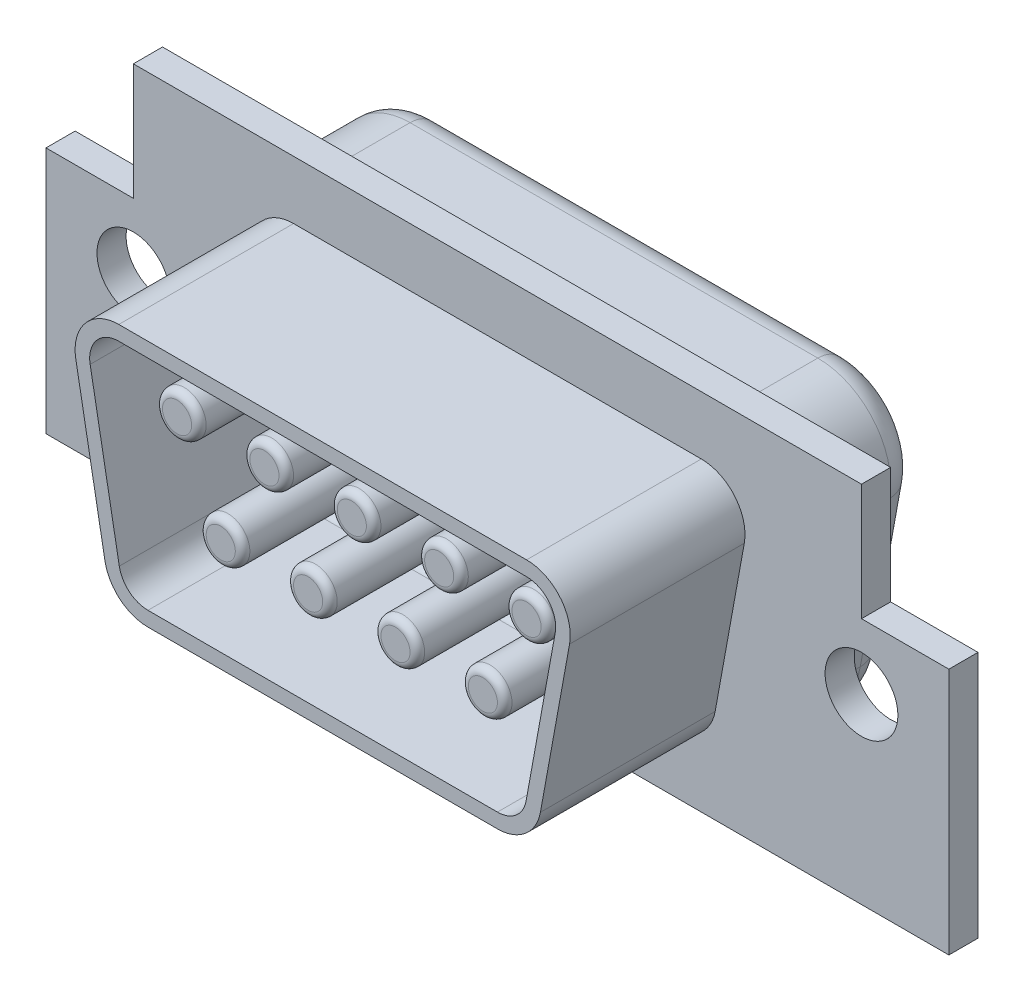
from build123d import *

# Parameters (mm, degrees)
SKETCH1_W                 = 31
SKETCH1_H                 = 12.5
EXTRUDE1_DEPTH            = 1
EXTRUDE2_DEPTH            = 6
M3X0_5_TAPPED_HOLE1_D     = 2.5
M3X0_5_TAPPED_HOLE1_DEPTH = 17.5
M3X0_5_TAPPED_HOLE1_TIP   = 0.751075774
EXTRUDE3_DEPTH            = 4
FILLET2_R                 = 1
EXTRUDE4_DEPTH            = 0.5
SKETCH10_W                = 6.420651052
SKETCH10_H                = 6.175896966
SKETCH10_W_2              = 7.637064352
SKETCH10_H_2              = 8.744155905
CUT_EXTRUDE1_DEPTH        = 5
SKETCH8_R                 = 0.75
EXTRUDE5_DEPTH            = 5
FILLET3_R                 = 0.25


with BuildPart() as part:
    # Sketch1 → Extrude1 (new body)
    with BuildSketch(Plane.XY):
        Rectangle(SKETCH1_W, SKETCH1_H)
    extrude(amount=EXTRUDE1_DEPTH)

    # Sketch2 → Extrude2 (add)
    with BuildSketch(Plane.XY.offset(1)):
        with BuildLine():
            Line((-6, -4.25), (6, -4.25))
            ThreePointArc((6, -4.25), (6.961121159, -3.901627595), (7.475804865, -3.018328157))
            Line((7.475804865, -3.018328157), (8.475804865, 2.481671843))
            ThreePointArc((8.475804865, 2.481671843), (8.151627595, 3.711121159), (7, 4.25))
            Line((7, 4.25), (-7, 4.25))
            ThreePointArc((-7, 4.25), (-8.151627595, 3.711121159), (-8.475804865, 2.481671843))
            Line((-8.475804865, 2.481671843), (-7.475804865, -3.018328157))
            ThreePointArc((-7.475804865, -3.018328157), (-6.961121159, -3.901627595), (-6, -4.25))
        make_face()
        with BuildLine():
            Line((-7, 3.75), (7, 3.75))
            ThreePointArc((7, 3.75), (7.76775173, 3.390747439), (7.98386991, 2.571114562))
            Line((7.98386991, 2.571114562), (6.98386991, -2.928885438))
            ThreePointArc((6.98386991, -2.928885438), (6.640747439, -3.51775173), (6, -3.75))
            Line((6, -3.75), (-6, -3.75))
            ThreePointArc((-6, -3.75), (-6.640747439, -3.51775173), (-6.98386991, -2.928885438))
            Line((-6.98386991, -2.928885438), (-7.98386991, 2.571114562))
            ThreePointArc((-7.98386991, 2.571114562), (-7.76775173, 3.390747439), (-7, 3.75))
        make_face(mode=Mode.SUBTRACT)
    extrude(amount=EXTRUDE2_DEPTH)

    # M3x0.5 Tapped Hole1
    with Locations(Plane(origin=(-12.5, 0, 1), x_dir=(1, 0, 0), z_dir=(0, 0, 1))):
        with Locations((0, 0), (25, 0)):
            Hole(M3X0_5_TAPPED_HOLE1_D / 2, depth=M3X0_5_TAPPED_HOLE1_DEPTH)
            with Locations((0, 0, -(M3X0_5_TAPPED_HOLE1_DEPTH + M3X0_5_TAPPED_HOLE1_TIP / 2))):  # 118° drill point
                Cone(0, M3X0_5_TAPPED_HOLE1_D / 2, M3X0_5_TAPPED_HOLE1_TIP, mode=Mode.SUBTRACT)

    # Sketch6 → Extrude3 (add)
    with BuildSketch(Plane(origin=(0, 0, 0), x_dir=(-1, 0, 0), z_dir=(0, 0, -1))):
        with BuildLine():
            Line((8.459674775, -3.197213595), (9.459674775, 2.302786405))
            ThreePointArc((9.459674775, 2.302786405), (8.919379325, 4.351868598), (7, 5.25))
            Line((7, 5.25), (-7, 5.25))
            ThreePointArc((-7, 5.25), (-8.919379325, 4.351868598), (-9.459674775, 2.302786405))
            Line((-9.459674775, 2.302786405), (-8.459674775, -3.197213595))
            ThreePointArc((-8.459674775, -3.197213595), (-7.601868598, -4.669379325), (-6, -5.25))
            Line((-6, -5.25), (6, -5.25))
            ThreePointArc((6, -5.25), (7.601868598, -4.669379325), (8.459674775, -3.197213595))
        make_face()
    extrude(amount=EXTRUDE3_DEPTH)

    # Fillet2
    fillet2_edges = [part.edges().sort_by_distance(p)[0] for p in [
        (-8.919379325, 4.351868598, -4),
        (0, 5.25, -4),
        (8.919379325, 4.351868598, -4),
        (8.959674775, -0.447213595, -4),
        (7.601868598, -4.669379325, -4),
        (0, -5.25, -4),
        (-7.601868598, -4.669379325, -4),
        (-8.959674775, -0.447213595, -4),
    ]]
    fillet(fillet2_edges, radius=FILLET2_R)

    # Sketch7 → Extrude4 (add)
    with BuildSketch(Plane(origin=(0, 0, -4), x_dir=(-1, 0, 0), z_dir=(0, 0, -1))):
        with BuildLine():
            Line((6.98386991, -2.928885438), (7.98386991, 2.571114562))
            ThreePointArc((7.98386991, 2.571114562), (7.76775173, 3.390747439), (7, 3.75))
            Line((7, 3.75), (-7, 3.75))
            ThreePointArc((-7, 3.75), (-7.76775173, 3.390747439), (-7.98386991, 2.571114562))
            Line((-7.98386991, 2.571114562), (-6.98386991, -2.928885438))
            ThreePointArc((-6.98386991, -2.928885438), (-6.640747439, -3.51775173), (-6, -3.75))
            Line((-6, -3.75), (6, -3.75))
            ThreePointArc((6, -3.75), (6.640747439, -3.51775173), (6.98386991, -2.928885438))
        make_face()
    extrude(amount=EXTRUDE4_DEPTH)

    # Sketch10 → Cut-Extrude1 (cut)
    with BuildSketch(Plane.XY.offset(1)):
        with Locations((-15.710325526, 5.337948483)):
            Rectangle(SKETCH10_W, SKETCH10_H)
        with Locations((16.318532176, 6.622077953)):
            Rectangle(SKETCH10_W_2, SKETCH10_H_2)
    extrude(amount=-CUT_EXTRUDE1_DEPTH, mode=Mode.SUBTRACT)

    # Sketch8 → Extrude5 (add)
    with BuildSketch(Plane.XY.offset(1)):
        with Locations((-6, 1.5)):
            Circle(SKETCH8_R)
        with Locations((-4.5, -1.5)):
            Circle(SKETCH8_R)
        with Locations((-3, 1.5)):
            Circle(SKETCH8_R)
        with Locations((1.5, -1.5)):
            Circle(SKETCH8_R)
        with Locations((0, 1.5)):
            Circle(SKETCH8_R)
        with Locations((-1.5, -1.5)):
            Circle(SKETCH8_R)
        with Locations((3, 1.5)):
            Circle(SKETCH8_R)
        with Locations((4.5, -1.5)):
            Circle(SKETCH8_R)
        with Locations((6, 1.5)):
            Circle(SKETCH8_R)
    extrude(amount=EXTRUDE5_DEPTH)

    # Fillet3
    fillet3_edges = [part.edges().sort_by_distance(p)[0] for p in [
        (-6.75, 1.5, 1),
        (-6.75, 1.5, 6),
        (-5.25, -1.5, 1),
        (-5.25, -1.5, 6),
        (-3.75, 1.5, 1),
        (-3.75, 1.5, 6),
        (0.75, -1.5, 1),
        (0.75, -1.5, 6),
        (-0.75, 1.5, 1),
        (-0.75, 1.5, 6),
        (-2.25, -1.5, 1),
        (-2.25, -1.5, 6),
        (2.25, 1.5, 1),
        (2.25, 1.5, 6),
        (3.75, -1.5, 1),
        (3.75, -1.5, 6),
        (5.25, 1.5, 1),
        (5.25, 1.5, 6),
        (0, 3.75, 1),
        (-7.76775173, 3.390747439, 1),
        (-7.48386991, -0.178885438, 1),
        (-6.640747439, -3.51775173, 1),
        (0, -3.75, 1),
        (6.640747439, -3.51775173, 1),
        (7.48386991, -0.178885438, 1),
        (7.76775173, 3.390747439, 1),
    ]]
    fillet(fillet3_edges, radius=FILLET3_R)


solid = part.part
